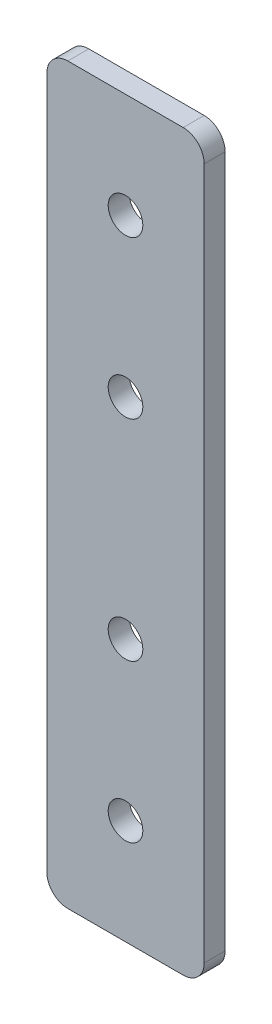
from build123d import *

# Parameters (mm, degrees)
SKETCH_1_W            = 15
SKETCH_1_H            = 70
EXTRUDE_1_DEPTH       = 2
HOLE_WIZARD_M41_D     = 3.3
HOLE_WIZARD_M41_DEPTH = 11.5
HOLE_WIZARD_M41_TIP   = 0.991420021
FILLET_1_R            = 2


with BuildPart() as part:
    # Эскиз1 → Бобышка-Вытянуть1 (new body)
    with BuildSketch(Plane.XY):
        Rectangle(SKETCH_1_W, SKETCH_1_H)
    extrude(amount=EXTRUDE_1_DEPTH)

    # Отверстие обработанное метчиком M41
    with Locations(Plane.XY.offset(2)):
        with Locations((0, 25), (0, -25), (0, -10), (0, 10)):
            Hole(HOLE_WIZARD_M41_D / 2, depth=HOLE_WIZARD_M41_DEPTH)
            with Locations((0, 0, -(HOLE_WIZARD_M41_DEPTH + HOLE_WIZARD_M41_TIP / 2))):  # 118° drill point
                Cone(0, HOLE_WIZARD_M41_D / 2, HOLE_WIZARD_M41_TIP, mode=Mode.SUBTRACT)

    # Скругление1
    fillet_1_edges = [part.edges().sort_by_distance(p)[0] for p in [
        (7.5, -35, 1),
        (-7.5, -35, 1),
        (-7.5, 35, 1),
        (7.5, 35, 1),
    ]]
    fillet(fillet_1_edges, radius=FILLET_1_R)


solid = part.part
